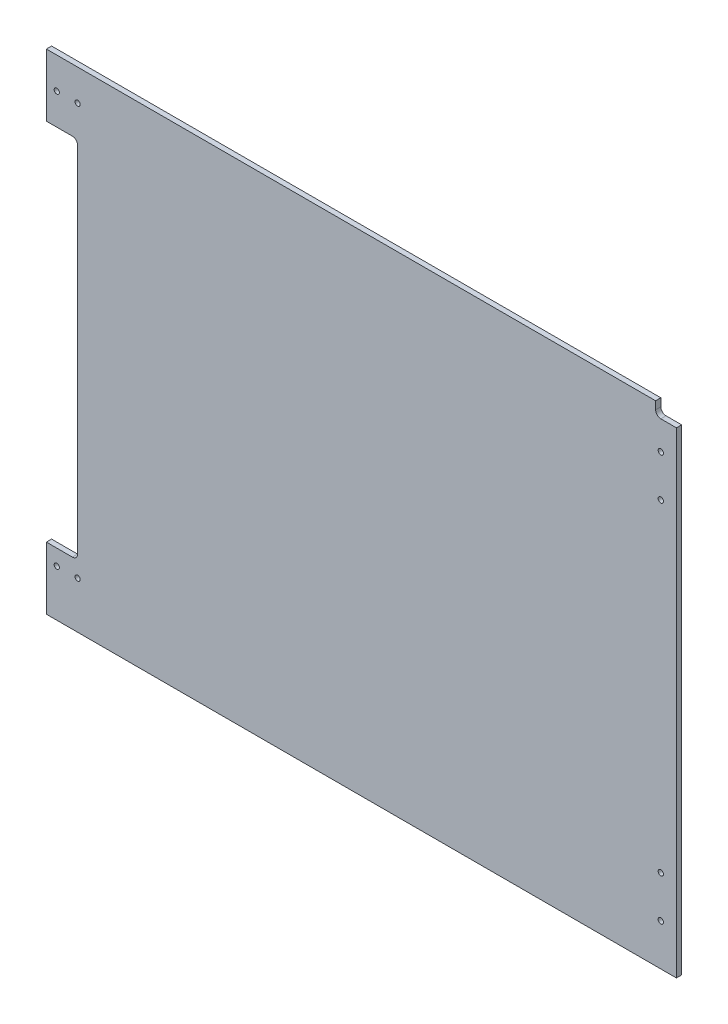
from build123d import *

# Parameters (mm, degrees)
SKETCH1_W                   = 736.6
SKETCH1_H                   = 596.9
BOSS_EXTRUDE1_DEPTH         = 6.35
SKETCH5_W                   = 31.75
SKETCH5_H                   = 76.2
BOSS_EXTRUDE2_DEPTH         = 6.35
SKETCH6_W                   = 6.35
SKETCH6_H                   = 444.5
CUT_EXTRUDE1_DEPTH          = 7.35
FILLET1_R                   = 6.35
F_0_257_DIAMETER_HOLE1_D    = 6.5278
F_1_4_0_25_DIAMETER_HOLE2_D = 6.35
CUT_EXTRUDE2_DEPTH          = 7.35


with BuildPart() as part:
    # Sketch1 → Boss-Extrude1 (new body)
    with BuildSketch(Plane.XY):
        Rectangle(SKETCH1_W, SKETCH1_H)
    extrude(amount=BOSS_EXTRUDE1_DEPTH)

    # Sketch5 → Boss-Extrude2 (add)
    with BuildSketch(Plane.XY.offset(6.35)):
        with Locations((-384.175, 260.35)):
            Rectangle(SKETCH5_W, SKETCH5_H)
        with Locations((-384.175, -260.35)):
            Rectangle(SKETCH5_W, SKETCH5_H)
    extrude(amount=-BOSS_EXTRUDE2_DEPTH)

    # Sketch6 → Cut-Extrude1 (cut, through all)
    with BuildSketch(Plane.XY.offset(6.35)):
        with Locations((-365.125, 0)):
            Rectangle(SKETCH6_W, SKETCH6_H)
    extrude(amount=-CUT_EXTRUDE1_DEPTH, mode=Mode.SUBTRACT)

    # Fillet1
    fillet1_edges = [part.edges().sort_by_distance(p)[0] for p in [
        (-361.95, -222.25, 3.175),
        (-361.95, 222.25, 3.175),
    ]]
    fillet(fillet1_edges, radius=FILLET1_R)

    # F (0.257) Diameter Hole1 (through all)
    with Locations(Plane.XY.offset(6.35)):
        with Locations((349.25, 247.65), (349.25, 196.85), (349.25, -196.85), (349.25, -247.65)):
            Hole(F_0_257_DIAMETER_HOLE1_D / 2)

    # 1/4 (0.25) Diameter Hole2 (through all)
    with Locations(Plane.XY.offset(6.35)):
        with Locations((-387.35, 260.35), (-361.95, 260.35), (-361.95, -241.3), (-387.35, -241.3)):
            Hole(F_1_4_0_25_DIAMETER_HOLE2_D / 2)

    # Sketch13 → Cut-Extrude2 (cut, through all)
    with BuildSketch(Plane.XY.offset(6.35)):
        with BuildLine():
            Line((368.3, 298.45), (342.9, 298.45))
            Line((342.9, 298.45), (342.9, 288.925))
            ThreePointArc((342.9, 288.925), (344.759871939, 284.434871939), (349.25, 282.575))
            Line((349.25, 282.575), (368.3, 282.575))
            Line((368.3, 282.575), (368.3, 298.45))
        make_face()
    extrude(amount=-CUT_EXTRUDE2_DEPTH, mode=Mode.SUBTRACT)


solid = part.part
